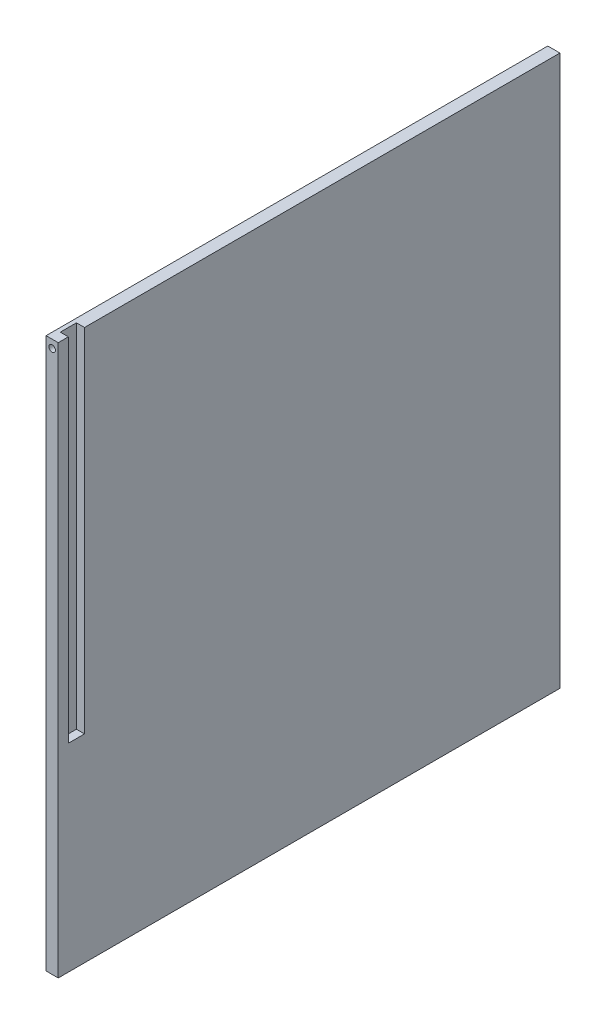
from build123d import *

# Parameters (mm, degrees)
SKETCH1_W           = 620
SKETCH1_H           = 680
BOSS_EXTRUDE1_DEPTH = 15
SKETCH2_R           = 4
CUT_EXTRUDE1_DEPTH  = 10
LPATTERN1_COUNT     = 3
LPATTERN1_PITCH     = 295
SKETCH3_R           = 4
CUT_EXTRUDE2_DEPTH  = 10
LPATTERN2_COUNT     = 3
LPATTERN2_PITCH     = 325
SKETCH7_R           = 4
CUT_EXTRUDE7_DEPTH  = 10
SKETCH8_W           = 10
SKETCH8_H           = 20
CUT_EXTRUDE8_DEPTH  = 435


with BuildPart() as part:
    # Sketch1 → Boss-Extrude1 (new body)
    with BuildSketch(Plane(origin=(0, 0, 0), x_dir=(0, 0, -1), z_dir=(1, 0, 0))):
        with Locations((0, 340)):
            Rectangle(SKETCH1_W, SKETCH1_H)
    extrude(amount=BOSS_EXTRUDE1_DEPTH)

    # Sketch2 → Cut-Extrude1 (cut)
    with BuildSketch(Plane.ZY):
        with Locations((295, 7.5)):
            Circle(SKETCH2_R)
    cut_extrude1 = extrude(amount=-CUT_EXTRUDE1_DEPTH, mode=Mode.SUBTRACT)

    # LPattern1: Cut-Extrude1 ×3
    with Locations(*[(0, 0, -i * LPATTERN1_PITCH) for i in range(1, LPATTERN1_COUNT)]):
        add(cut_extrude1, mode=Mode.SUBTRACT)

    # Sketch3 → Cut-Extrude2 (cut)
    with BuildSketch(Plane(origin=(0, 0, -310), x_dir=(-1, 0, 0), z_dir=(0, 0, -1))):
        with Locations((-7.5, 15)):
            Circle(SKETCH3_R)
    cut_extrude2 = extrude(amount=-CUT_EXTRUDE2_DEPTH, mode=Mode.SUBTRACT)

    # LPattern2: Cut-Extrude2 ×3
    with Locations(*[(0, i * LPATTERN2_PITCH, 0) for i in range(1, LPATTERN2_COUNT)]):
        add(cut_extrude2, mode=Mode.SUBTRACT)

    # Sketch7 → Cut-Extrude7 (cut)
    with BuildSketch(Plane.XY.offset(310)):
        with Locations((7.5, 670)):
            Circle(SKETCH7_R)
    extrude(amount=-CUT_EXTRUDE7_DEPTH, mode=Mode.SUBTRACT)

    # Sketch8 → Cut-Extrude8 (cut)
    with BuildSketch(Plane(origin=(0, 680, 0), x_dir=(1, 0, 0), z_dir=(0, 1, 0))):
        with Locations((10, -287.5)):
            Rectangle(SKETCH8_W, SKETCH8_H)
    extrude(amount=-CUT_EXTRUDE8_DEPTH, mode=Mode.SUBTRACT)


solid = part.part
